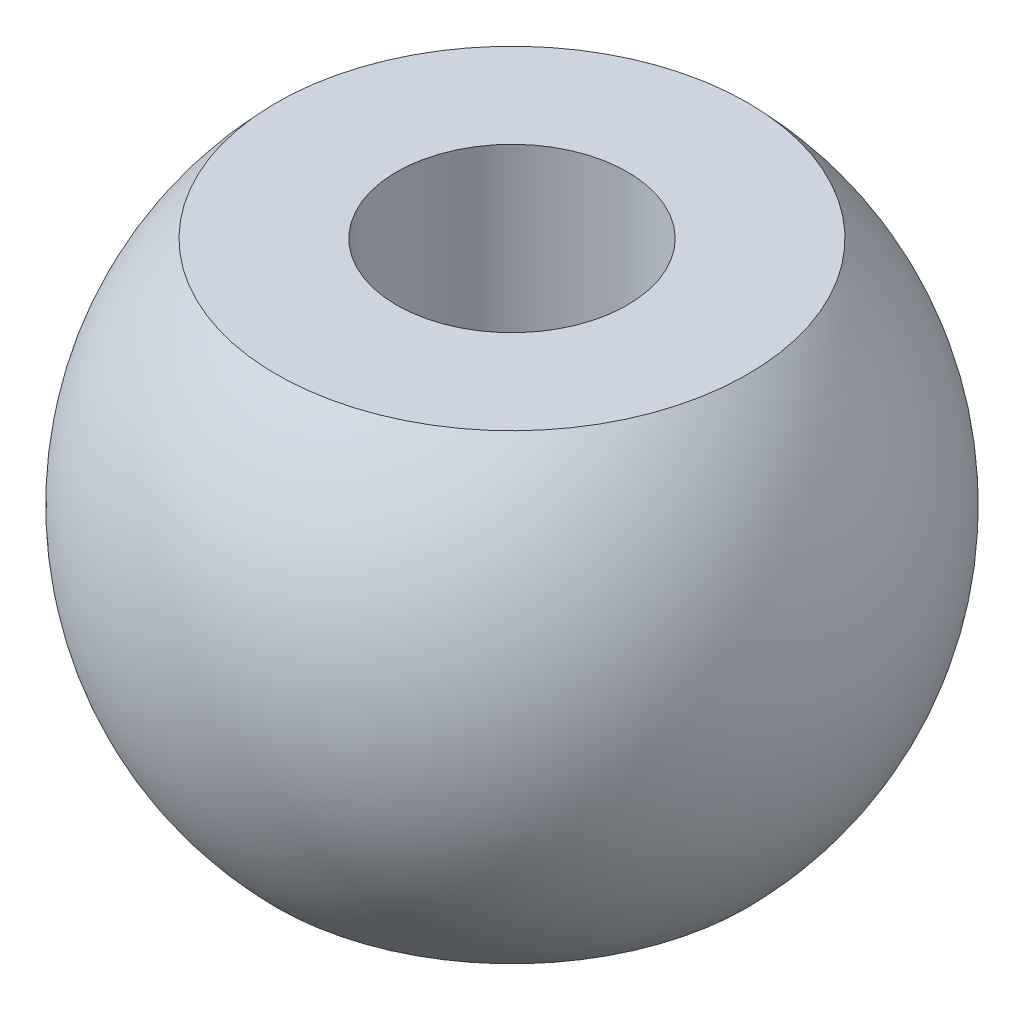
from build123d import *

# Parameters (mm, degrees)
CUT_EXTRUDE1_DEPTH      = 11
CUT_EXTRUDE1_DEPTH_BACK = 11
SKETCH4_R               = 3.5
CUT_EXTRUDE2_DEPTH      = 15


with BuildPart() as part:
    # Sketch1 → Revolve1 (revolve)
    with BuildSketch(Plane.XY):
        with BuildLine():
            ThreePointArc((0, 20), (10, 10), (0, 0))
            Line((0, 0), (0, 20))
        make_face()
    revolve(axis=Axis((0, 0, 0), (0, 1, 0)))

    # Sketch3 → Cut-Extrude1 (cut, two sides)
    with BuildSketch(Plane.XY) as cut_extrude1_sk:
        Polygon((0, 17), (-8.309800503, 17), (-8.309800503, 20), (9.435235491, 20), (9.435235491, 17), align=None)
        Polygon((0, 0), (9.435235491, 0), (9.435235491, 3), (-8.578664685, 3), (-8.578664685, 0), align=None)
    extrude(amount=CUT_EXTRUDE1_DEPTH, mode=Mode.SUBTRACT)
    extrude(cut_extrude1_sk.sketch, amount=-CUT_EXTRUDE1_DEPTH_BACK, mode=Mode.SUBTRACT)

    # Sketch4 → Cut-Extrude2 (cut, through all)
    with BuildSketch(Plane(origin=(0, 17, 0), x_dir=(1, 0, 0), z_dir=(0, 1, 0))):
        Circle(SKETCH4_R)
    extrude(amount=-CUT_EXTRUDE2_DEPTH, mode=Mode.SUBTRACT)


solid = part.part
